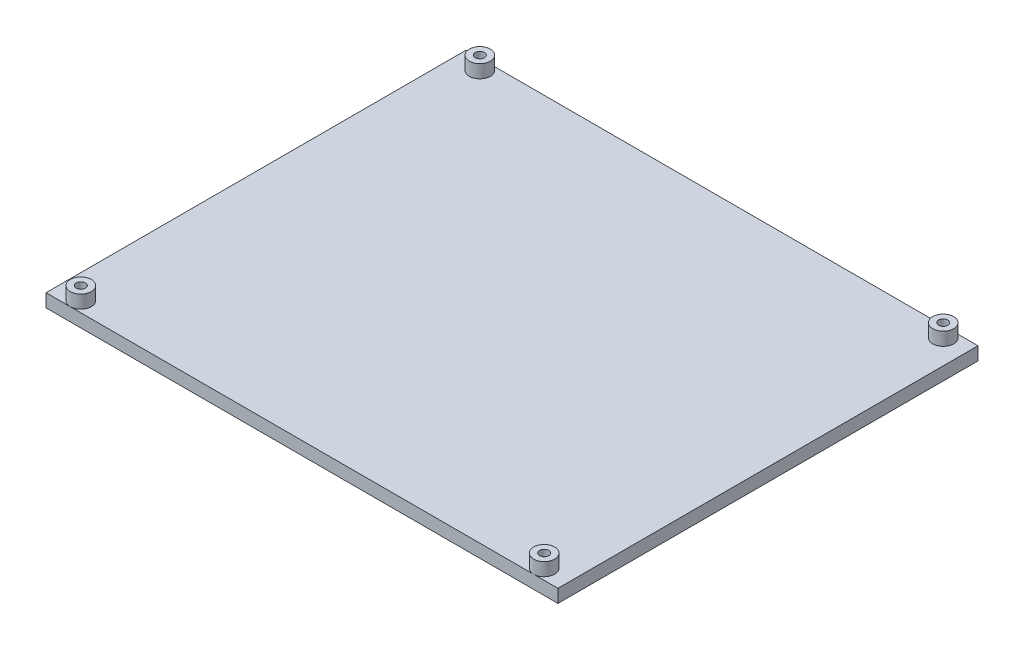
from build123d import *

# Parameters (mm, degrees)
SKETCH1_R           = 1.75
BOSS_EXTRUDE1_DEPTH = 5
SKETCH2_R           = 4
SKETCH2_R_2         = 1.75
BOSS_EXTRUDE2_DEPTH = 5


with BuildPart() as part:
    # Sketch1 → Boss-Extrude1 (new body)
    with BuildSketch(Plane(origin=(0, 0, 0), x_dir=(1, 0, 0), z_dir=(0, 1, 0))):
        Polygon((-92.5, -80), (92.5, -80), (97.5, -80), (97.5, 80), (92.5, 80), (-92.5, 80), (-97.5, 80), (-97.5, -80), align=None)
        with Locations((-88.25, 76)):
            Circle(SKETCH1_R, mode=Mode.SUBTRACT)
        with Locations((88.25, 76)):
            Circle(SKETCH1_R, mode=Mode.SUBTRACT)
        with Locations((88.25, -76)):
            Circle(SKETCH1_R, mode=Mode.SUBTRACT)
        with Locations((-88.25, -76)):
            Circle(SKETCH1_R, mode=Mode.SUBTRACT)
    extrude(amount=BOSS_EXTRUDE1_DEPTH)

    # Sketch2 → Boss-Extrude2 (add)
    with BuildSketch(Plane(origin=(0, 5, 0), x_dir=(1, 0, 0), z_dir=(0, 1, 0))):
        with Locations((-88.25, 76)):
            Circle(SKETCH2_R)
        with Locations((-88.25, 76)):
            Circle(SKETCH2_R_2, mode=Mode.SUBTRACT)
        with Locations((88.25, 76)):
            Circle(SKETCH2_R)
        with Locations((88.25, 76)):
            Circle(SKETCH2_R_2, mode=Mode.SUBTRACT)
        with Locations((88.25, -76)):
            Circle(SKETCH2_R)
        with Locations((88.25, -76)):
            Circle(SKETCH2_R_2, mode=Mode.SUBTRACT)
        with Locations((-88.25, -76)):
            Circle(SKETCH2_R)
        with Locations((-88.25, -76)):
            Circle(SKETCH2_R_2, mode=Mode.SUBTRACT)
    extrude(amount=BOSS_EXTRUDE2_DEPTH)


solid = part.part
